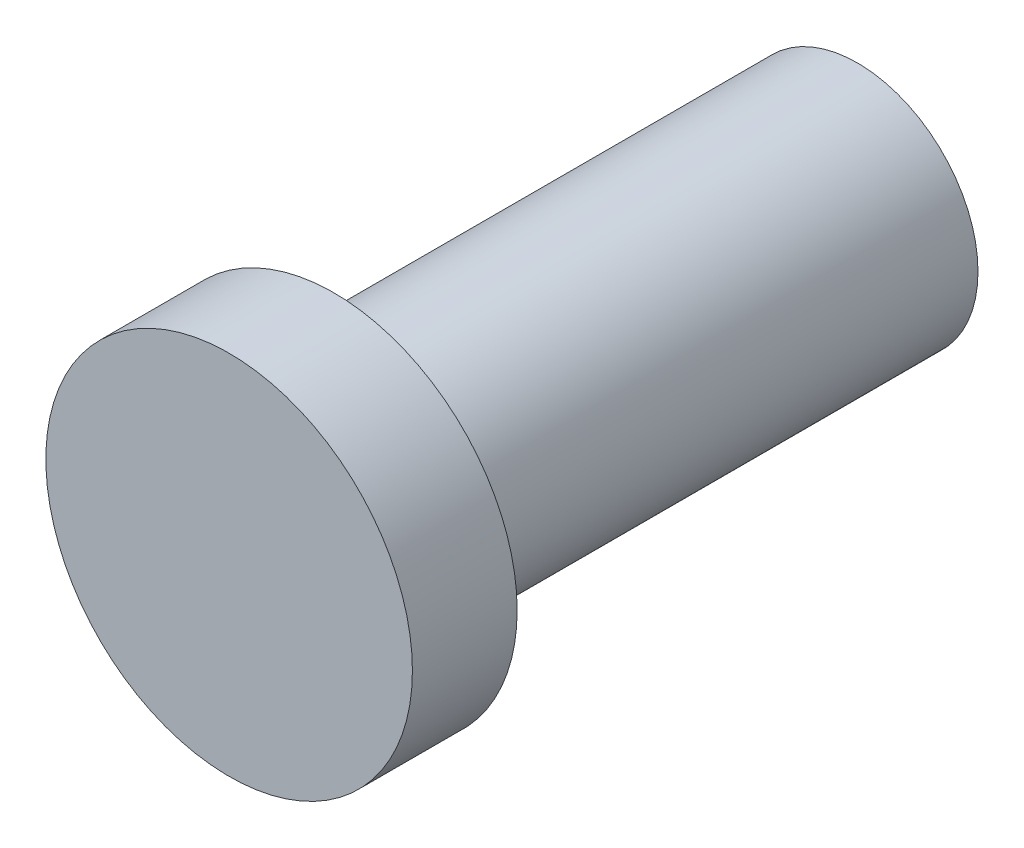
from build123d import *

# Parameters (mm, degrees)
SKETCH_1_R      = 1.15
EXTRUDE_1_DEPTH = 5
SKETCH_2_R      = 1.75
EXTRUDE_2_DEPTH = 1


with BuildPart() as part:
    # 草图1 → 凸台-拉伸1 (new body)
    with BuildSketch(Plane.XY):
        Circle(SKETCH_1_R)
    extrude(amount=EXTRUDE_1_DEPTH)

    # 草图2 → 凸台-拉伸2 (add)
    with BuildSketch(Plane.XY.offset(5)):
        Circle(SKETCH_2_R)
    extrude(amount=EXTRUDE_2_DEPTH)


solid = part.part
